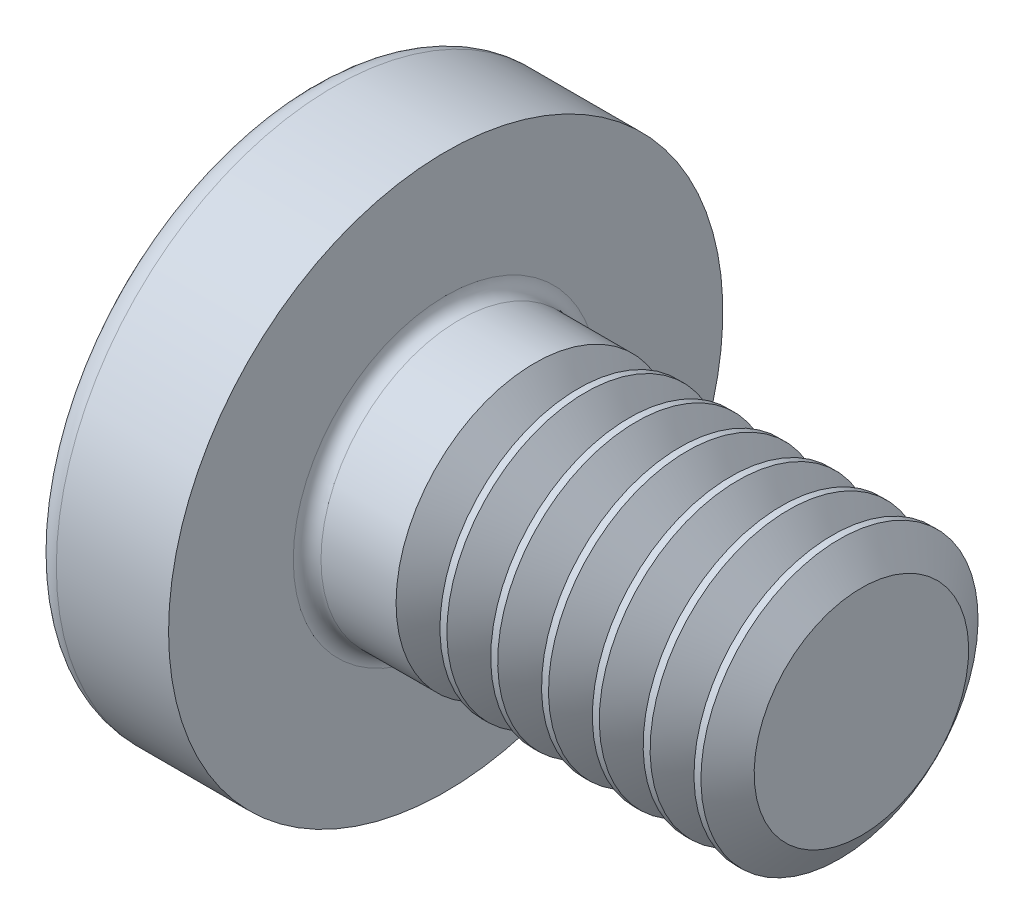
from build123d import *

# Parameters (mm, degrees)
FILLET1_R       = 0.1
SKETCH3_W       = 0.48
SKETCH3_H       = 2.1
SKETCH4_W       = 0.48
SKETCH4_H       = 0.68402847
RECPAT_COUNT    = 2
RECPAT_ANGLE    = 90
THDSCHPAT_COUNT = 7
THDSCHPAT_PITCH = 0.366666667


with BuildPart() as part:
    # BodySke → Base-Revolve (revolve)
    with BuildSketch(Plane.XY, mode=Mode.PRIVATE) as base_revolve_sk:
        with BuildLine():
            Line((1.6, 1), (1.6, 2))
            Line((1.6, 2), (0.790020747, 2))
            ThreePointArc((0.790020747, 2), (0.709789294, 1.981130115), (0.646379599, 1.928476821))
            ThreePointArc((0.646379599, 1.928476821), (0.165895084, 1.016959861), (0, 0))
            Line((0, 0), (4.6, 0))
            Line((4.6, 0), (4.6, 1))
            Line((4.6, 1), (1.6, 1))
        make_face()
    revolve(base_revolve_sk.sketch.rotate(Axis((-25.4, 0, 0), (1, 0, 0)), 90), axis=Axis((-25.4, 0, 0), (1, 0, 0)))  # turned: the seam where the file's is

    # Fillet1
    fillet1_edges = [part.edges().sort_by_distance(p)[0] for p in [
        (1.6, 0, -1),
    ]]
    fillet(fillet1_edges, radius=FILLET1_R)

    # Sketch3 → Recess section 0
    with BuildSketch(Plane(origin=(0, 0, 0), x_dir=(0, 0, -1), z_dir=(1, 0, 0))):
        Rectangle(SKETCH3_W, SKETCH3_H)
    # Sketch4 → Recess section 1
    with BuildSketch(Plane(origin=(1.42, 0, 0), x_dir=(0, 0, -1), z_dir=(1, 0, 0))):
        Rectangle(SKETCH4_W, SKETCH4_H)
    recess = loft(mode=Mode.SUBTRACT)

    # RecPat: Recess ×2 about axis
    recpat_axis = Axis((0, 0, 0), (1, 0, 0))
    for i in range(1, RECPAT_COUNT):
        add(recess.rotate(recpat_axis, i * RECPAT_ANGLE / (RECPAT_COUNT - 1)), mode=Mode.SUBTRACT)

    # RecCorSke → RecessCore (revolve, cut)
    with BuildSketch(Plane.XY, mode=Mode.PRIVATE) as recesscore_sk:
        Polygon((0, 0), (0, 0.454796073), (1.42, 0.3555), (1.535508952, 0), align=None)
    revolve(recesscore_sk.sketch.rotate(Axis((-3.175, 0, 0), (1, 0, 0)), 90), axis=Axis((-3.175, 0, 0), (1, 0, 0)), mode=Mode.SUBTRACT)  # turned: the seam where the file's is

    # ThdSchSke → ThreadSchematic (revolve, cut)
    with BuildSketch(Plane.XY, mode=Mode.PRIVATE) as threadschematic_sk:
        Polygon((2.4, -0.774), (2.241753096, -1), (2.241753096, -1.25), (2.558246904, -1.25), (2.558246904, -1), align=None)
    threadschematic = revolve(threadschematic_sk.sketch.rotate(Axis((-3.175, 0, 0), (1, 0, 0)), 270), axis=Axis((-3.175, 0, 0), (1, 0, 0)), mode=Mode.SUBTRACT)  # turned: the seam where the file's is

    # ThdSchPat: ThreadSchematic ×7
    with Locations(*[(i * THDSCHPAT_PITCH, 0, 0) for i in range(1, THDSCHPAT_COUNT)]):
        add(threadschematic, mode=Mode.SUBTRACT)


solid = part.part
